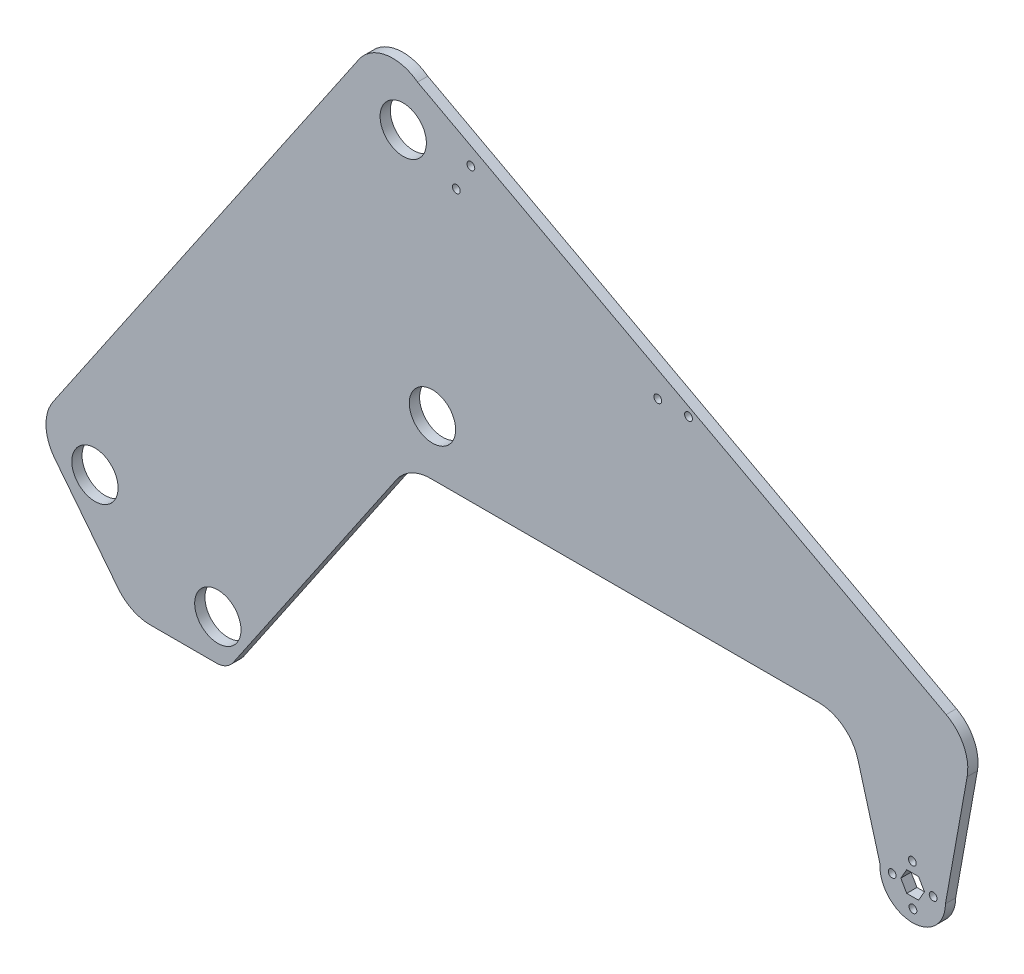
from build123d import *

# Parameters (mm, degrees)
MODEL_R             = 14.351
MODEL_R_2           = 2.413
BOSS_EXTRUDE1_DEPTH = 6.35


with BuildPart() as part:
    # Model → Boss-Extrude1 (new body)
    with BuildSketch(Plane.XY):
        with BuildLine():
            ThreePointArc((-212.899365952, 93.541257838), (-203.778989185, 101.701881024), (-191.901103209, 104.650248016))
            Line((-191.901103209, 104.650248016), (48.661197018, 104.650248016))
            ThreePointArc((48.661197018, 104.650248016), (64.032332507, 99.471232012), (73.135172194, 86.046168785))
            Line((73.135172194, 86.046168785), (86.727013732, 37.098218434))
            ThreePointArc((86.727013732, 37.098218434), (106.36258142, 15.501750179), (127.326236921, 35.811553418))
            Line((127.326236921, 35.811553418), (140.807890588, 110.809453484))
            ThreePointArc((140.807890588, 110.809453484), (138.675228362, 126.361225539), (127.809114585, 137.689660276))
            Line((127.809114585, 137.689660276), (-44.466784077, 230.040741354))
            Line((-44.466784077, 230.040741354), (-154.507929168, 289.02994873))
            Line((-154.507929168, 289.02994873), (-199.949582693, 313.389629113))
            ThreePointArc((-199.949582693, 313.389629113), (-219.402189514, 318.224062751), (-236.303247901, 307.447705012))
            Line((-236.303247901, 307.447705012), (-425.920878295, 28.83612519))
            ThreePointArc((-425.920878295, 28.83612519), (-430.307847502, 13.679090678), (-424.898106806, -1.143726181))
            Line((-424.898106806, -1.143726181), (-385.58146606, -51.20282143))
            ThreePointArc((-385.58146606, -51.20282143), (-376.71145599, -58.357541068), (-365.605974805, -60.913979882))
            Line((-365.605974805, -60.913979882), (-324.737451002, -60.913979882))
            ThreePointArc((-324.737451002, -60.913979882), (-318.798508014, -59.439796386), (-314.23831963, -55.359484793))
            Line((-314.23831963, -55.359484793), (-212.899365952, 93.541257838))
        make_face()
        with Locations((-323.775189267, -35.513979882)):
            Circle(MODEL_R, mode=Mode.SUBTRACT)
        with Locations((-399.975189267, 2.586020118)):
            Circle(MODEL_R, mode=Mode.SUBTRACT)
        with Locations((107.189078625, 23.111553418)):
            Circle(MODEL_R_2, mode=Mode.SUBTRACT)
        with Locations((94.306236921, 35.628711714)):
            Circle(MODEL_R_2, mode=Mode.SUBTRACT)
        Polygon((110.67241113, 42.161553418), (114.338585339, 35.811553418), (110.67241113, 29.461553418), (103.340062711, 29.461553418), (99.673888502, 35.811553418), (103.340062711, 42.161553418), (106.823395217, 42.161553418), align=None, mode=Mode.SUBTRACT)
        with Locations((119.706236921, 35.994395122)):
            Circle(MODEL_R_2, mode=Mode.SUBTRACT)
        with Locations((106.823395217, 48.511553418)):
            Circle(MODEL_R_2, mode=Mode.SUBTRACT)
        with Locations((-190.707148919, 138.516914683)):
            Circle(MODEL_R, mode=Mode.SUBTRACT)
        with Locations((-175.899669139, 268.100247422)):
            Circle(MODEL_R_2, mode=Mode.SUBTRACT)
        with Locations((-208.832932893, 283.437784316)):
            Circle(MODEL_R, mode=Mode.SUBTRACT)
        with Locations((-166.899276125, 284.889989099)):
            Circle(MODEL_R_2, mode=Mode.SUBTRACT)
        with Locations((-51.007069668, 217.840195735)):
            Circle(MODEL_R_2, mode=Mode.SUBTRACT)
        with Locations((-31.957069668, 217.840195735)):
            Circle(MODEL_R_2, mode=Mode.SUBTRACT)
    extrude(amount=BOSS_EXTRUDE1_DEPTH)


solid = part.part
